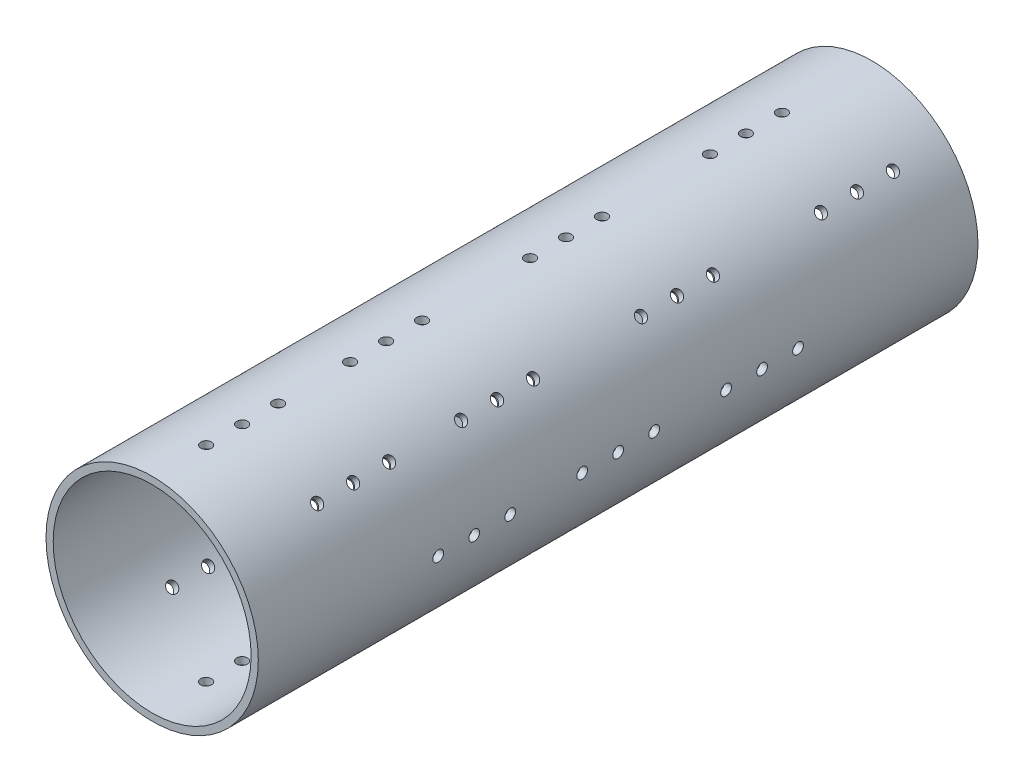
from build123d import *

# Parameters (mm, degrees)
SKETCH1_R           = 29.5
SKETCH1_R_2         = 27.5
BOSS_EXTRUDE1_DEPTH = 100
SKETCH2_R           = 1.5
CUT_EXTRUDE1_DEPTH  = 30.5
SKETCH3_R           = 1.5
CUT_EXTRUDE2_DEPTH  = 30.5000001
CUT_EXTRUDE3_START  = -42.719300244
SKETCH6_R           = 1.5
CUT_EXTRUDE3_DEPTH  = 85.438600486
CUT_EXTRUDE4_START  = -42.719300244
SKETCH7_R           = 1.5
CUT_EXTRUDE4_DEPTH  = 85.438600486
LPATTERN1_COUNT     = 3
LPATTERN1_PITCH     = 50
LPATTERN1_COL_COUNT = 2
LPATTERN1_COL_PITCH = 40
LPATTERN2_COUNT     = 3
LPATTERN2_PITCH     = 40
LPATTERN2_COL_COUNT = 2
LPATTERN2_COL_PITCH = 40
LPATTERN3_COUNT     = 2
LPATTERN3_PITCH     = 40
LPATTERN3_COL_COUNT = 2
LPATTERN3_COL_PITCH = 40


with BuildPart() as part:
    # Sketch1 → Boss-Extrude1 (new body, symmetric)
    with BuildSketch(Plane.XY):
        Circle(SKETCH1_R)
        Circle(SKETCH1_R_2, mode=Mode.SUBTRACT)
    extrude(amount=BOSS_EXTRUDE1_DEPTH, both=True)

    # Sketch2 → Cut-Extrude1 (cut, symmetric)
    with BuildSketch(Plane(origin=(0, 0, 0), x_dir=(1, 0, 0), z_dir=(0, 1, 0))):
        with Locations((0, -45)):
            Circle(SKETCH2_R)
        with Locations((0, -35)):
            Circle(SKETCH2_R)
        with Locations((0, -25)):
            Circle(SKETCH2_R)
    cut_extrude1 = extrude(amount=CUT_EXTRUDE1_DEPTH, both=True, mode=Mode.SUBTRACT)

    # Sketch3 → Cut-Extrude2 (cut, symmetric)
    with BuildSketch(Plane(origin=(0, 0, 0), x_dir=(0, 0, -1), z_dir=(1, 0, 0))):
        with Locations((-10, 0)):
            Circle(SKETCH3_R)
        Circle(SKETCH3_R)
        with Locations((10, 0)):
            Circle(SKETCH3_R)
    cut_extrude2 = extrude(amount=CUT_EXTRUDE2_DEPTH, both=True, mode=Mode.SUBTRACT)

    # Sketch6 → Cut-Extrude3 (cut)
    with BuildSketch(Plane(origin=(0, 0, 0), x_dir=(0, 0, -1), z_dir=(0.707106781, 0.707106781, 0)).offset(CUT_EXTRUDE3_START)):
        with Locations((-15, 0)):
            Circle(SKETCH6_R)
        with Locations((-25, 0)):
            Circle(SKETCH6_R)
        with Locations((-35, 0)):
            Circle(SKETCH6_R)
    cut_extrude3 = extrude(amount=CUT_EXTRUDE3_DEPTH, mode=Mode.SUBTRACT)

    # Sketch7 → Cut-Extrude4 (cut)
    with BuildSketch(Plane(origin=(0, 0, 0), x_dir=(0, 0, -1), z_dir=(0.707106781, -0.707106781, 0)).offset(CUT_EXTRUDE4_START)):
        with Locations((35, 0)):
            Circle(SKETCH7_R)
        with Locations((25, 0)):
            Circle(SKETCH7_R)
        with Locations((15, 0)):
            Circle(SKETCH7_R)
    cut_extrude4 = extrude(amount=CUT_EXTRUDE4_DEPTH, mode=Mode.SUBTRACT)

    # LPattern1: Cut-Extrude1, Cut-Extrude3 ×3
    with Locations(*[(0, 0, -i * LPATTERN1_PITCH) for i in range(1, LPATTERN1_COUNT)]):
        add(cut_extrude1, mode=Mode.SUBTRACT)
        add(cut_extrude3, mode=Mode.SUBTRACT)

    # LPattern1 col: Cut-Extrude1, Cut-Extrude3 ×2
    with Locations(*[(0, 0, i * LPATTERN1_COL_PITCH) for i in range(1, LPATTERN1_COL_COUNT)]):
        add(cut_extrude1, mode=Mode.SUBTRACT)
        add(cut_extrude3, mode=Mode.SUBTRACT)

    # LPattern2: Cut-Extrude4 ×3
    with Locations(*[(0, 0, i * LPATTERN2_PITCH) for i in range(1, LPATTERN2_COUNT)]):
        add(cut_extrude4, mode=Mode.SUBTRACT)

    # LPattern2 col: Cut-Extrude4 ×2
    with Locations(*[(0, 0, -i * LPATTERN2_COL_PITCH) for i in range(1, LPATTERN2_COL_COUNT)]):
        add(cut_extrude4, mode=Mode.SUBTRACT)

    # LPattern3: Cut-Extrude2 ×2
    with Locations(*[(0, 0, -i * LPATTERN3_PITCH) for i in range(1, LPATTERN3_COUNT)]):
        add(cut_extrude2, mode=Mode.SUBTRACT)

    # LPattern3 col: Cut-Extrude2 ×2
    with Locations(*[(0, 0, i * LPATTERN3_COL_PITCH) for i in range(1, LPATTERN3_COL_COUNT)]):
        add(cut_extrude2, mode=Mode.SUBTRACT)


solid = part.part
